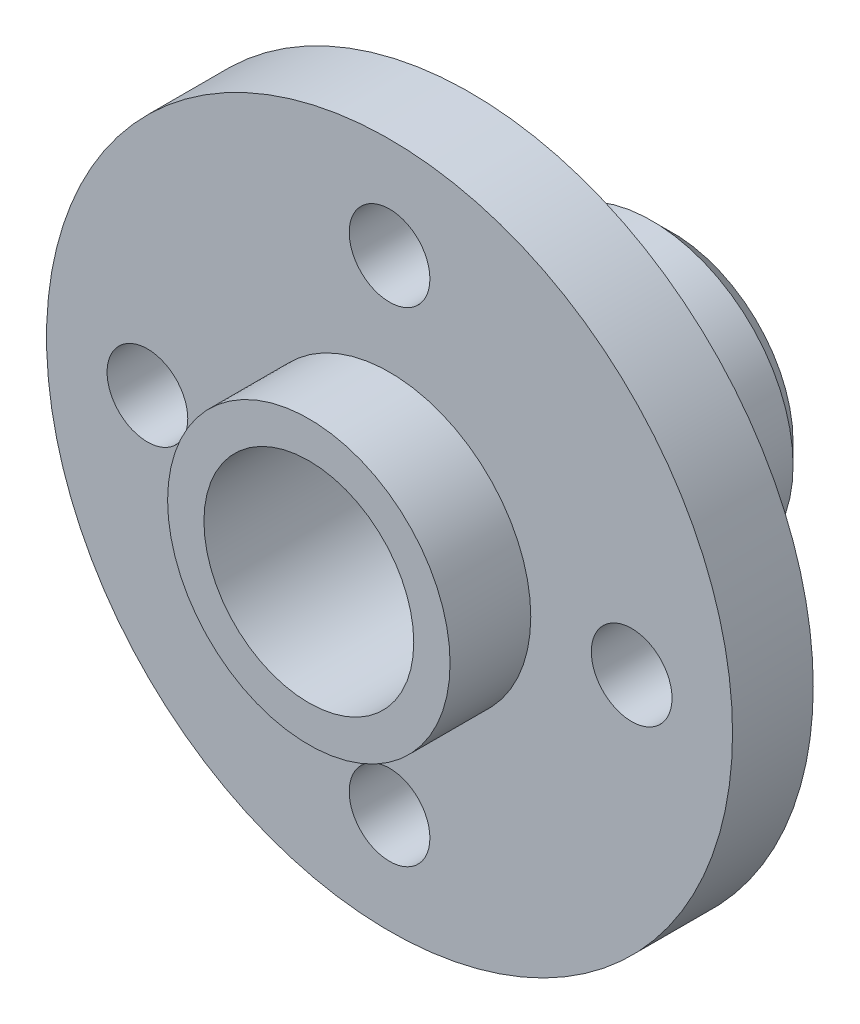
from build123d import *

# Parameters (mm, degrees)
SKETCH_2_R      = 8.5
SKETCH_2_R_2    = 2.6
SKETCH_2_R_3    = 1
EXTRUDE_1_DEPTH = 2
SKETCH_3_R      = 3.5
SKETCH_3_R_2    = 2.6
EXTRUDE_2_DEPTH = 2
SKETCH_4_R      = 3.5
SKETCH_4_R_2    = 2.6
EXTRUDE_3_DEPTH = 5
CHAMFER_1_SIZE  = 0.5


with BuildPart() as part:
    # Эскиз2 → Бобышка-Вытянуть1 (new body)
    with BuildSketch(Plane.XY):
        Circle(SKETCH_2_R)
        Circle(SKETCH_2_R_2, mode=Mode.SUBTRACT)
        with Locations((-6, 0)):
            Circle(SKETCH_2_R_3, mode=Mode.SUBTRACT)
        with Locations((0, 6)):
            Circle(SKETCH_2_R_3, mode=Mode.SUBTRACT)
        with Locations((6, 0)):
            Circle(SKETCH_2_R_3, mode=Mode.SUBTRACT)
        with Locations((0, -6)):
            Circle(SKETCH_2_R_3, mode=Mode.SUBTRACT)
    extrude(amount=EXTRUDE_1_DEPTH)

    # Эскиз3 → Бобышка-Вытянуть2 (add)
    with BuildSketch(Plane.XY.offset(2)):
        Circle(SKETCH_3_R)
        Circle(SKETCH_3_R_2, mode=Mode.SUBTRACT)
    extrude(amount=EXTRUDE_2_DEPTH)

    # Эскиз4 → Бобышка-Вытянуть3 (add)
    with BuildSketch(Plane(origin=(0, 0, 0), x_dir=(-1, 0, 0), z_dir=(0, 0, -1))):
        Circle(SKETCH_4_R)
        Circle(SKETCH_4_R_2, mode=Mode.SUBTRACT)
    extrude(amount=EXTRUDE_3_DEPTH)

    # Фаска1
    chamfer_1_edges = [part.edges().sort_by_distance(p)[0] for p in [
        (3.5, 0, -5),
    ]]
    chamfer(chamfer_1_edges, length=CHAMFER_1_SIZE)


solid = part.part
